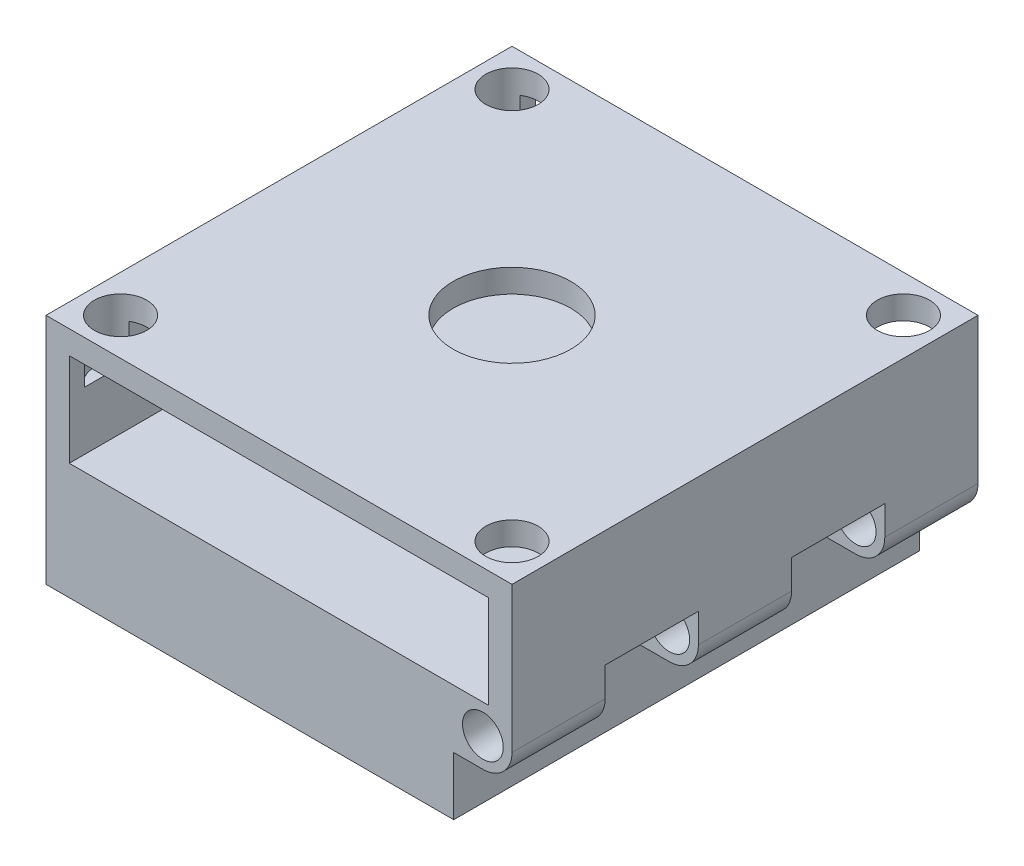
from build123d import *

# Parameters (mm, degrees)
SKETCH2_W                = 50.8
SKETCH2_H                = 50.8
BOSS_EXTRUDE1_DEPTH      = 19.05
SHELL1_T                 = -2.54
SKETCH4_R                = 6.4135
SKETCH4_R_2              = 2.8575
CUT_EXTRUDE1_DEPTH       = 6.35
SKETCH5_W                = 6.35
SKETCH5_H                = 6.35
BOSS_EXTRUDE3_DEPTH      = 50.8
SKETCH6_R                = 2.2225
CUT_EXTRUDE2_DEPTH       = 51.8
SKETCH7_W                = 10.16
SKETCH7_H                = 6.35
CUT_EXTRUDE3_DEPTH       = 6.35
FILLET1_R                = 3.175
SKETCH8_R                = 6.4135
CUT_EXTRUDE4_DEPTH       = 6.35
SKETCH9_W                = 44.45
SKETCH9_H                = 50.8
SKETCH9_R                = 6.4135
BOSS_EXTRUDE4_DEPTH      = 6.35
BOSS_EXTRUDE4_DEPTH_BACK = 6.35


with BuildPart() as part:
    # Sketch2 → Boss-Extrude1 (new body)
    with BuildSketch(Plane(origin=(0, 0, 0), x_dir=(1, 0, 0), z_dir=(0, 1, 0))):
        with Locations((25.4, 25.4)):
            Rectangle(SKETCH2_W, SKETCH2_H)
    extrude(amount=BOSS_EXTRUDE1_DEPTH)

    # Shell1
    shell1_openings = [part.faces().sort_by_distance(p)[0] for p in [
        (25.4, 9.525, -50.8),
        (25.4, 9.525, 0),
    ]]
    offset(amount=SHELL1_T, openings=shell1_openings, kind=Kind.INTERSECTION)

    # Sketch4 → Cut-Extrude1 (cut)
    with BuildSketch(Plane(origin=(0, 19.05, 0), x_dir=(1, 0, 0), z_dir=(0, 1, 0))):
        with Locations((25.4, 25.4)):
            Circle(SKETCH4_R)
        with Locations((4.064, 46.736)):
            Circle(SKETCH4_R_2)
        with Locations((46.736, 46.736)):
            Circle(SKETCH4_R_2)
        with Locations((46.736, 4.064)):
            Circle(SKETCH4_R_2)
        with Locations((4.064, 4.064)):
            Circle(SKETCH4_R_2)
    extrude(amount=-CUT_EXTRUDE1_DEPTH, mode=Mode.SUBTRACT)

    # Sketch5 → Boss-Extrude3 (add)
    with BuildSketch(Plane.XY):
        with Locations((47.625, 3.175)):
            Rectangle(SKETCH5_W, SKETCH5_H)
    extrude(amount=-BOSS_EXTRUDE3_DEPTH)

    # Sketch6 → Cut-Extrude2 (cut, through all)
    with BuildSketch(Plane.XY):
        with Locations((47.625, 3.175)):
            Circle(SKETCH6_R)
    extrude(amount=-CUT_EXTRUDE2_DEPTH, mode=Mode.SUBTRACT)

    # Sketch7 → Cut-Extrude3 (cut)
    with BuildSketch(Plane(origin=(50.8, 0, 0), x_dir=(0, 0, -1), z_dir=(1, 0, 0))):
        with Locations((15.24, 3.175)):
            Rectangle(SKETCH7_W, SKETCH7_H)
        with Locations((35.56, 3.175)):
            Rectangle(SKETCH7_W, SKETCH7_H)
    extrude(amount=-CUT_EXTRUDE3_DEPTH, mode=Mode.SUBTRACT)

    # Fillet1
    fillet1_edges = [part.edges().sort_by_distance(p)[0] for p in [
        (50.8, 0, -25.4),
        (50.8, 0, -45.72),
        (50.8, 0, -5.08),
    ]]
    fillet(fillet1_edges, radius=FILLET1_R)

    # Sketch8 → Cut-Extrude4 (cut)
    with BuildSketch(Plane(origin=(0, 2.54, 0), x_dir=(1, 0, 0), z_dir=(0, 1, 0))):
        with Locations((25.4, 25.4)):
            Circle(SKETCH8_R)
    extrude(amount=-CUT_EXTRUDE4_DEPTH, mode=Mode.SUBTRACT)

    # Sketch9 → Boss-Extrude4 (add, two sides)
    with BuildSketch(Plane.XZ) as boss_extrude4_sk:
        with Locations((22.225, -25.4)):
            Rectangle(SKETCH9_W, SKETCH9_H)
        with Locations((25.4, -25.4)):
            Circle(SKETCH9_R, mode=Mode.SUBTRACT)
    extrude(amount=BOSS_EXTRUDE4_DEPTH)
    extrude(boss_extrude4_sk.sketch, amount=-BOSS_EXTRUDE4_DEPTH_BACK)


solid = part.part
